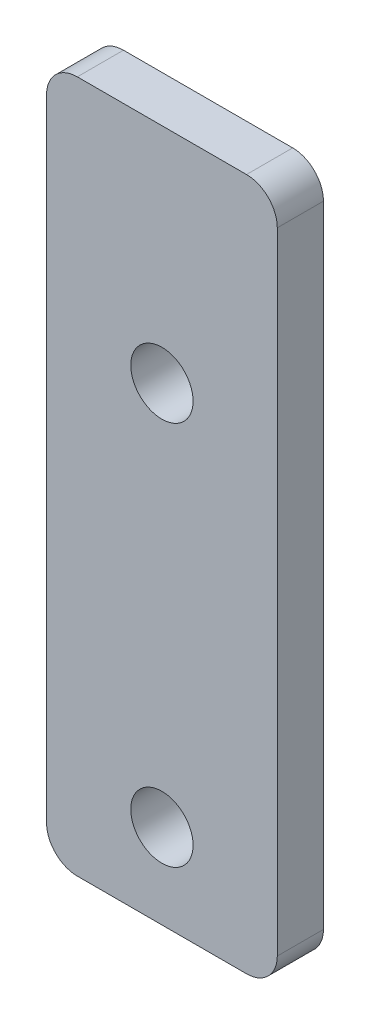
from build123d import *

# Parameters (mm, degrees)
SKETCH_1_W          = 15
SKETCH_1_H          = 45
EXTRUDE_1_DEPTH     = 3
SKETCH_2_R          = 2.025
CUT_EXTRUDE_1_DEPTH = 3
FILLET_1_R          = 2


with BuildPart() as part:
    # 草图1 → 凸台-拉伸1 (new body)
    with BuildSketch(Plane.XY):
        Rectangle(SKETCH_1_W, SKETCH_1_H)
    extrude(amount=EXTRUDE_1_DEPTH)

    # 草图2 → 切除-拉伸1 (cut)
    with BuildSketch(Plane.XY.offset(3)):
        with Locations((0, -17)):
            Circle(SKETCH_2_R)
        with Locations((0, 8)):
            Circle(SKETCH_2_R)
    extrude(amount=-CUT_EXTRUDE_1_DEPTH, mode=Mode.SUBTRACT)

    # 圆角1
    fillet_1_edges = [part.edges().sort_by_distance(p)[0] for p in [
        (7.5, -22.5, 1.5),
        (-7.5, -22.5, 1.5),
        (-7.5, 22.5, 1.5),
        (7.5, 22.5, 1.5),
    ]]
    fillet(fillet_1_edges, radius=FILLET_1_R)


solid = part.part
